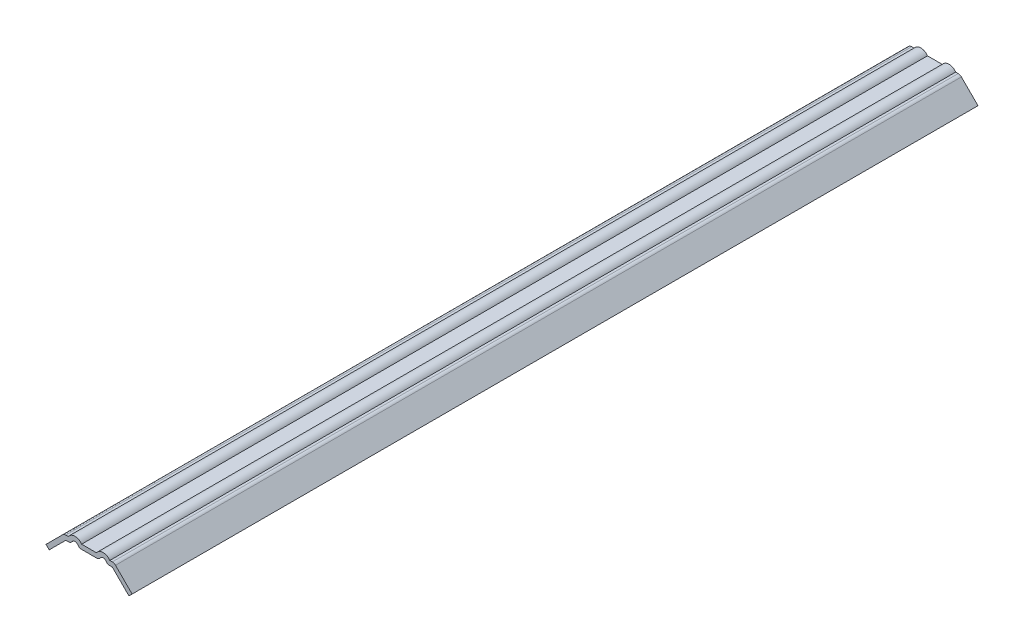
from build123d import *

# Parameters (mm, degrees)
EXTRUDE_THIN1_DEPTH = 571.5
FILLET1_R           = 3.048


with BuildPart() as part:
    # Sketch1 → Extrude-Thin1 (new body)
    with BuildSketch(Plane.XY):
        with BuildLine():
            Line((0, 38.166088515), (-7.14375, 38.166088515))
            ThreePointArc((-7.14375, 38.166088515), (-9.525, 40.547338515), (-11.90625, 38.166088515))
            Line((-11.90625, 38.166088515), (-15.715448212, 38.166088515))
            Line((-15.715448212, 38.166088515), (-26.940768363, 26.940768363))
            Line((-26.940768363, 26.940768363), (-29.096029832, 29.096029832))
            Line((-29.096029832, 29.096029832), (-16.97797115, 41.214088515))
            Line((-16.97797115, 41.214088515), (-14.017933514, 41.214088515))
            ThreePointArc((-14.017933514, 41.214088515), (-9.525, 43.595338515), (-5.032066486, 41.214088515))
            Line((-5.032066486, 41.214088515), (0, 41.214088515))
            Line((0, 41.214088515), (0, 38.166088515))
        make_face()
    extrude(amount=-EXTRUDE_THIN1_DEPTH)

    # Fillet1
    fillet1_edges = [part.edges().sort_by_distance(p)[0] for p in [
        (-16.97797115, 41.214088515, -285.75),
        (-7.14375, 38.166088515, -285.75),
        (-11.90625, 38.166088515, -285.75),
    ]]
    fillet(fillet1_edges, radius=FILLET1_R)

    # Mirror1: part across plane


with BuildPart() as part_1:
    add(part.part)
    add(part.part.mirror(Plane(origin=(0, 41.214088515, -571.5), x_dir=(0, 0, 1), z_dir=(-1, 0, 0))))


solid = part_1.part
